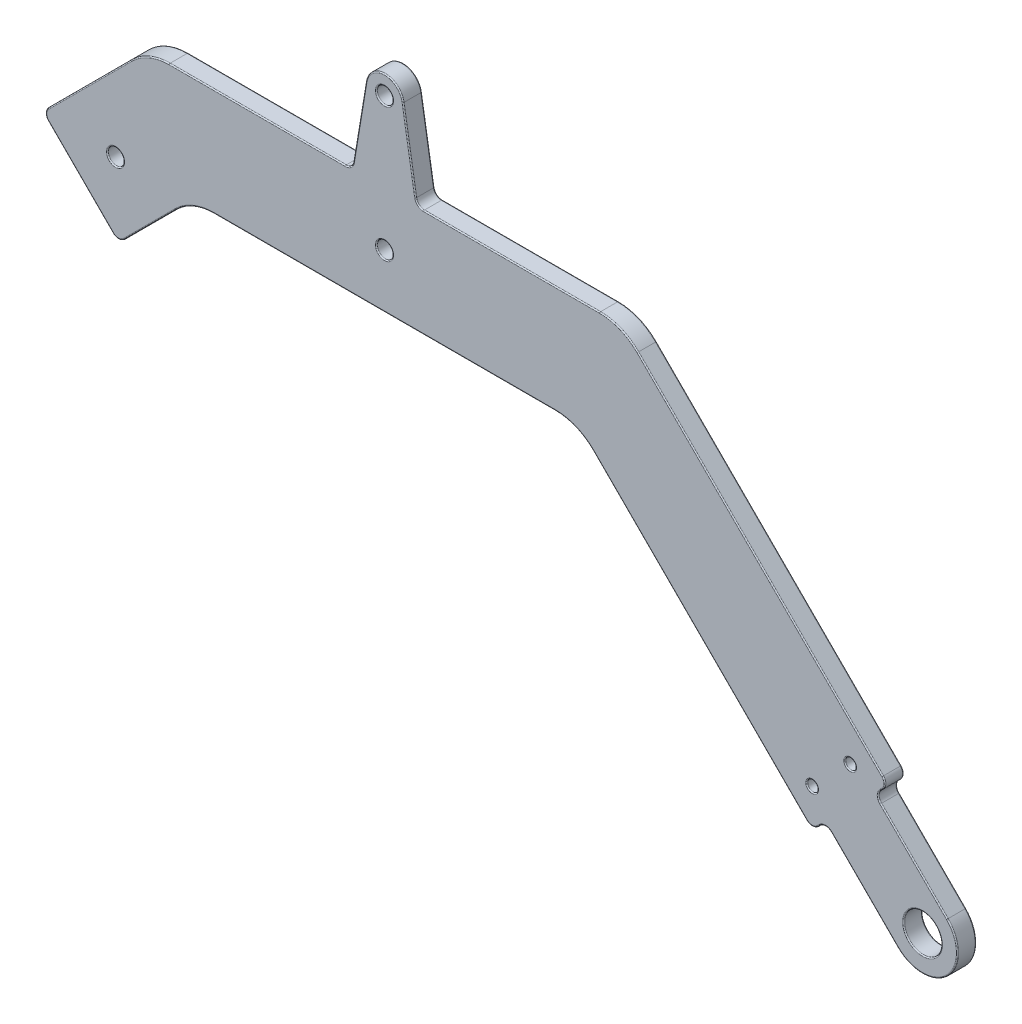
from build123d import *

# Parameters (mm, degrees)
SKETCH5_R           = 3.5
SKETCH5_R_2         = 1.5
SKETCH5_R_3         = 1
BOSS_EXTRUDE1_DEPTH = 3.5
FILLET1_R           = 10
FILLET2_R           = 1.5
FILLET3_R           = 0.2


with BuildPart() as part:
    # Sketch5 → Boss-Extrude1 (new body)
    with BuildSketch(Plane.XY):
        with BuildLine():
            Line((104.596194078, 4.596194078), (91.161165235, 18.03122292))
            Line((91.161165235, 18.03122292), (93.636038969, 20.506096654))
            Line((93.636038969, 20.506096654), (44.142135624, 70))
            Line((44.142135624, 70), (6, 70))
            Line((6, 70), (3.453220204, 85.420324662))
            ThreePointArc((3.453220204, 85.420324662), (0, 88.35), (-3.453220204, 85.420324662))
            Line((-3.453220204, 85.420324662), (-6, 70))
            Line((-6, 70), (-44.142135624, 70))
            Line((-44.142135624, 70), (-63.587572106, 50.554563517))
            Line((-63.587572106, 50.554563517), (-49.445436483, 36.412427894))
            Line((-49.445436483, 36.412427894), (-35.857864376, 50))
            Line((-35.857864376, 50), (35.857864376, 50))
            Line((35.857864376, 50), (79.493903346, 6.363961031))
            Line((79.493903346, 6.363961031), (81.96877708, 8.838834765))
            Line((81.96877708, 8.838834765), (95.403805922, -4.596194078))
            ThreePointArc((95.403805922, -4.596194078), (104.596194078, -4.596194078), (104.596194078, 4.596194078))
        make_face()
        with Locations((100, 0)):
            Circle(SKETCH5_R, mode=Mode.SUBTRACT)
        with Locations((0, 60)):
            Circle(SKETCH5_R_2, mode=Mode.SUBTRACT)
        with Locations((0, 84.85)):
            Circle(SKETCH5_R_2, mode=Mode.SUBTRACT)
        with Locations((86.564971157, 20.506096654)):
            Circle(SKETCH5_R_3, mode=Mode.SUBTRACT)
        with Locations((79.493903346, 13.435028843)):
            Circle(SKETCH5_R_3, mode=Mode.SUBTRACT)
        with Locations((-50, 50)):
            Circle(SKETCH5_R_2, mode=Mode.SUBTRACT)
    extrude(amount=-BOSS_EXTRUDE1_DEPTH)

    # Fillet1
    fillet1_edges = [part.edges().sort_by_distance(p)[0] for p in [
        (44.142135624, 70, -1.75),
        (35.857864376, 50, -1.75),
        (-35.857864376, 50, -1.75),
        (-44.142135624, 70, -1.75),
    ]]
    fillet(fillet1_edges, radius=FILLET1_R)

    # Fillet2
    fillet2_edges = [part.edges().sort_by_distance(p)[0] for p in [
        (93.636038969, 20.506096654, -1.75),
        (91.161165235, 18.03122292, -1.75),
        (81.96877708, 8.838834765, -1.75),
        (79.493903346, 6.363961031, -1.75),
        (-49.445436483, 36.412427894, -1.75),
        (-63.587572106, 50.554563517, -1.75),
        (-6, 70, -1.75),
        (6, 70, -1.75),
    ]]
    fillet(fillet2_edges, radius=FILLET2_R)

    # Fillet3
    fillet3_edges = [part.edges().sort_by_distance(p)[0] for p in [
        (0, 88.35, -3.5),
        (-23.636292033, 70, 0),
        (-43.585786438, 42.272077939, 0),
        (80.731340213, 7.601397898, 0),
        (89.216621587, 1.590990258, 0),
        (92.398602102, 19.268659787, 0),
        (79.493903346, 6.985281374, 0),
        (93.014718626, 20.506096654, 0),
        (-62.966251763, 50.554563517, 0),
        (-49.445436483, 37.033748237, 0),
        (-43.585786438, 42.272077939, -3.5),
        (69.823223305, 44.318912319, -3.5),
        (92.398602102, 19.268659787, -3.5),
        (89.216621587, 1.590990258, -3.5),
        (80.731340213, 7.601397898, -3.5),
        (-23.636292033, 70, -3.5),
        (4.622926377, 78.337949903, -3.5),
        (79.493903346, 6.985281374, -3.5),
        (93.014718626, 20.506096654, -3.5),
        (-62.966251763, 50.554563517, -3.5),
        (-49.445436483, 37.033748237, -3.5),
        (-6.302181387, 70.356182427, 0),
        (-6.302181387, 70.356182427, -3.5),
        (6.302181387, 70.356182427, 0),
        (6.302181387, 70.356182427, -3.5),
        (91.782485579, 18.03122292, 0),
        (91.782485579, 18.03122292, -3.5),
        (81.96877708, 8.217514421, 0),
        (81.96877708, 8.217514421, -3.5),
        (-4.622926377, 78.337949903, -3.5),
        (98.409009742, 10.783378413, 0),
        (104.596194078, -4.596194078, 0),
        (-4.622926377, 78.337949903, 0),
        (0, 88.35, 0),
        (96.5, 0, -3.5),
        (96.5, 0, 0),
        (104.596194078, -4.596194078, -3.5),
        (-1.5, 60, -3.5),
        (-1.5, 60, 0),
        (98.409009742, 10.783378413, -3.5),
        (-1.5, 84.85, -3.5),
        (-1.5, 84.85, 0),
        (85.564971157, 20.506096654, -3.5),
        (85.564971157, 20.506096654, 0),
        (78.493903346, 13.435028843, -3.5),
        (78.493903346, 13.435028843, 0),
        (-51.5, 50, -3.5),
        (-51.5, 50, 0),
        (0, 50, 0),
        (0, 50, -3.5),
        (58.610019869, 27.247844507, 0),
        (58.610019869, 27.247844507, -3.5),
        (23.636292033, 70, 0),
        (-54.798989873, 59.343145751, 0),
        (-43.826834324, 69.238795325, 0),
        (43.826834324, 69.238795325, 0),
        (23.636292033, 70, -3.5),
        (-54.798989873, 59.343145751, -3.5),
        (-43.826834324, 69.238795325, -3.5),
        (43.826834324, 69.238795325, -3.5),
        (-35.542563076, 49.238795325, 0),
        (-35.542563076, 49.238795325, -3.5),
        (35.542563076, 49.238795325, 0),
        (35.542563076, 49.238795325, -3.5),
        (-56.516504294, 43.483495706, 0),
        (-56.516504294, 43.483495706, -3.5),
        (69.823223305, 44.318912319, 0),
        (4.622926377, 78.337949903, 0),
    ]]
    fillet(fillet3_edges, radius=FILLET3_R)


solid = part.part
